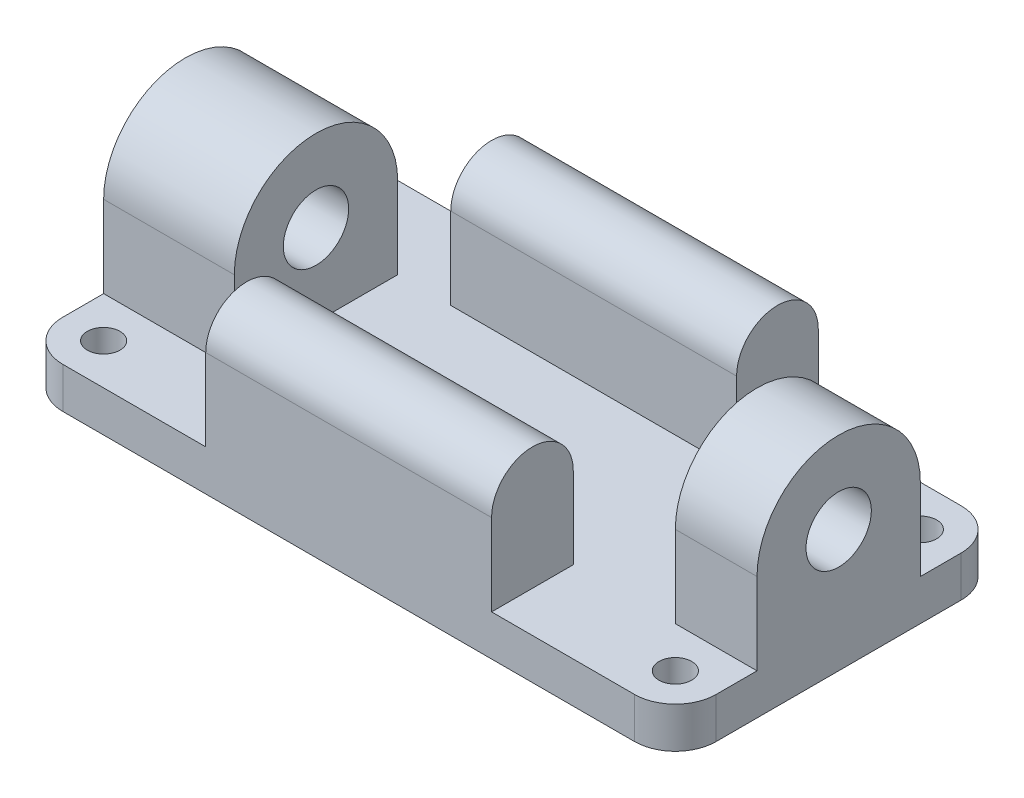
from build123d import *

# Parameters (mm, degrees)
SKETCH1_R           = 2
BOSS_EXTRUDE1_DEPTH = 5
BOSS_EXTRUDE2_DEPTH = 10
SKETCH3_R           = 4
CUT_EXTRUDE1_DEPTH  = 16
BOSS_EXTRUDE3_DEPTH = 16
SKETCH5_R           = 4
CUT_EXTRUDE2_DEPTH  = 23
SKETCH7_W           = 35
SKETCH7_H           = 10
BOSS_EXTRUDE4_DEPTH = 10
BOSS_EXTRUDE5_DEPTH = 35
SKETCH10_W          = 35
SKETCH10_H          = 10
BOSS_EXTRUDE6_DEPTH = 10
BOSS_EXTRUDE7_DEPTH = 35


with BuildPart() as part:
    # Sketch1 → Boss-Extrude1 (new body)
    with BuildSketch(Plane(origin=(0, 0, 0), x_dir=(1, 0, 0), z_dir=(0, 1, 0))):
        with BuildLine():
            Line((-35, 20), (35, 20))
            ThreePointArc((35, 20), (38.535533906, 18.535533906), (40, 15))
            Line((40, 15), (40, -15))
            ThreePointArc((40, -15), (38.535533906, -18.535533906), (35, -20))
            Line((35, -20), (-35, -20))
            ThreePointArc((-35, -20), (-38.535533906, -18.535533906), (-40, -15))
            Line((-40, -15), (-40, 15))
            ThreePointArc((-40, 15), (-38.535533906, 18.535533906), (-35, 20))
        make_face()
        with Locations((-35, 15)):
            Circle(SKETCH1_R, mode=Mode.SUBTRACT)
        with Locations((-35, -15)):
            Circle(SKETCH1_R, mode=Mode.SUBTRACT)
        with Locations((35, 15)):
            Circle(SKETCH1_R, mode=Mode.SUBTRACT)
        with Locations((35, -15)):
            Circle(SKETCH1_R, mode=Mode.SUBTRACT)
    extrude(amount=BOSS_EXTRUDE1_DEPTH)

    # Sketch2 → Boss-Extrude2 (add)
    with BuildSketch(Plane(origin=(40, 0, 0), x_dir=(0, 0, -1), z_dir=(1, 0, 0))):
        with BuildLine():
            ThreePointArc((10, 15), (0, 25), (-10, 15))
            Line((-10, 15), (-10, 0))
            Line((-10, 0), (10, 0))
            Line((10, 0), (10, 15))
        make_face()
    extrude(amount=-BOSS_EXTRUDE2_DEPTH)

    # Sketch3 → Cut-Extrude1 (cut)
    with BuildSketch(Plane(origin=(40, 0, 0), x_dir=(0, 0, -1), z_dir=(1, 0, 0))):
        with Locations((0, 15)):
            Circle(SKETCH3_R)
    extrude(amount=-CUT_EXTRUDE1_DEPTH, mode=Mode.SUBTRACT)

    # Sketch4 → Boss-Extrude3 (add)
    with BuildSketch(Plane.ZY.offset(40)):
        with BuildLine():
            Line((0, 0), (-10, 0))
            Line((-10, 0), (-10, 15))
            ThreePointArc((-10, 15), (0, 25), (10, 15))
            Line((10, 15), (10, 0))
            Line((10, 0), (0, 0))
        make_face()
    extrude(amount=-BOSS_EXTRUDE3_DEPTH)

    # Sketch5 → Cut-Extrude2 (cut)
    with BuildSketch(Plane.ZY.offset(40)):
        with Locations((0, 15)):
            Circle(SKETCH5_R)
    extrude(amount=-CUT_EXTRUDE2_DEPTH, mode=Mode.SUBTRACT)

    # Sketch7 → Boss-Extrude4 (add)
    with BuildSketch(Plane(origin=(0, 5, 0), x_dir=(1, 0, 0), z_dir=(0, 1, 0))):
        with Locations((0, 15)):
            Rectangle(SKETCH7_W, SKETCH7_H)
    extrude(amount=BOSS_EXTRUDE4_DEPTH)

    # Sketch8 → Boss-Extrude5 (add)
    with BuildSketch(Plane.ZY.offset(17.5)):
        with BuildLine():
            Line((-20, 15), (-10, 15))
            ThreePointArc((-10, 15), (-15, 20), (-20, 15))
        make_face()
    extrude(amount=-BOSS_EXTRUDE5_DEPTH)

    # Sketch10 → Boss-Extrude6 (add)
    with BuildSketch(Plane(origin=(0, 5, 0), x_dir=(1, 0, 0), z_dir=(0, 1, 0))):
        with Locations((0, -15)):
            Rectangle(SKETCH10_W, SKETCH10_H)
    extrude(amount=BOSS_EXTRUDE6_DEPTH)

    # Sketch11 → Boss-Extrude7 (add)
    with BuildSketch(Plane(origin=(17.5, 0, 0), x_dir=(0, 0, -1), z_dir=(1, 0, 0))):
        with BuildLine():
            Line((-20, 15), (-10, 15))
            ThreePointArc((-10, 15), (-15, 20), (-20, 15))
        make_face()
    extrude(amount=-BOSS_EXTRUDE7_DEPTH)


solid = part.part
